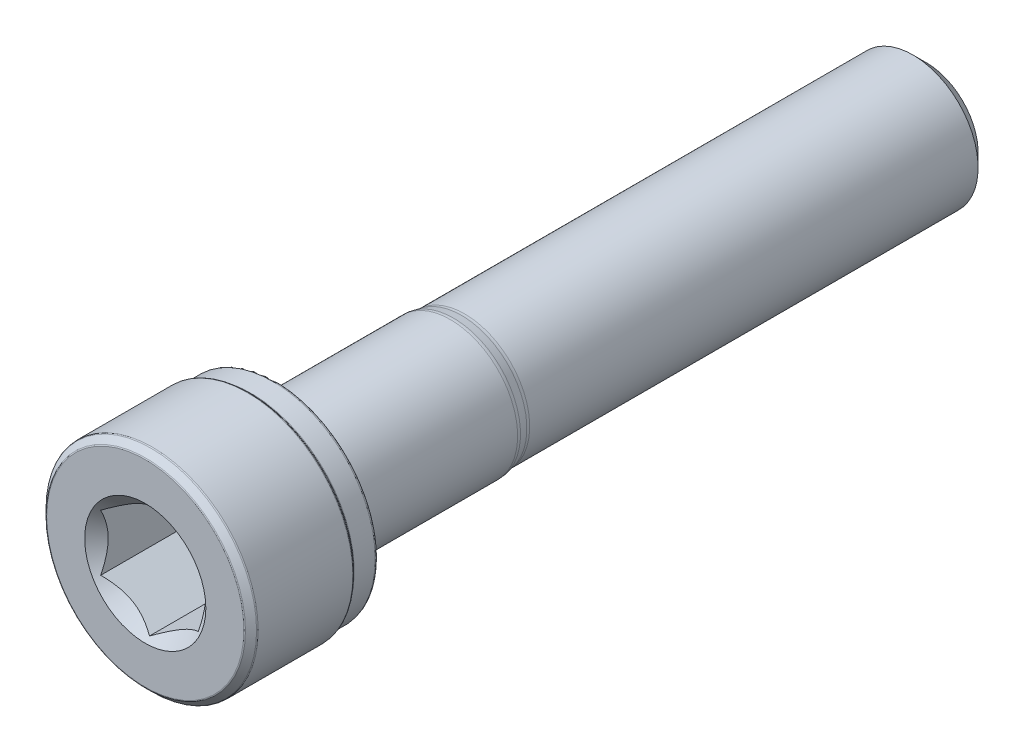
from build123d import *

# Parameters (mm, degrees)
CUT_EXTRUDE1_DEPTH = 7


with BuildPart() as part:
    # Sketch2 → Revolve1 (revolve)
    with BuildSketch(Plane(origin=(0, 0, 0), x_dir=(0, 0, -1), z_dir=(1, 0, 0)), mode=Mode.PRIVATE) as revolve1_sk:
        with BuildLine():
            Line((-24, 0), (-24, 6.058578644))
            ThreePointArc((-24, 6.058578644), (-23.992387953, 6.096846987), (-23.970710678, 6.129289322))
            Line((-23.970710678, 6.129289322), (-23.629289322, 6.470710678))
            ThreePointArc((-23.629289322, 6.470710678), (-23.596846987, 6.492387953), (-23.558578644, 6.5))
            Line((-23.558578644, 6.5), (-17.741421356, 6.5))
            ThreePointArc((-17.741421356, 6.5), (-17.703153013, 6.492387953), (-17.670710678, 6.470710678))
            Line((-17.670710678, 6.470710678), (-17.529289322, 6.329289322))
            ThreePointArc((-17.529289322, 6.329289322), (-17.496846987, 6.307612047), (-17.458578644, 6.3))
            Line((-17.458578644, 6.3), (-16.1625, 6.3))
            ThreePointArc((-16.1625, 6.3), (-16.047595148, 6.252404852), (-16, 6.1375))
            Line((-16, 6.1375), (-16, 4.535316469))
            ThreePointArc((-16, 4.535316469), (-15.882842712, 4.252473757), (-15.6, 4.135316469))
            Line((-15.6, 4.135316469), (-5.247523234, 4.135316469))
            ThreePointArc((-5.247523234, 4.135316469), (-5.149506093, 4.130501196), (-5.052432912, 4.11610175))
            Line((-5.052432912, 4.11610175), (-4.565348919, 4.01921472))
            ThreePointArc((-4.565348919, 4.01921472), (-4.468275737, 4.004815273), (-4.370258597, 4))
            Line((-4.370258597, 4), (23.188101184, 4))
            Line((23.188101184, 4), (24, 3.188101184))
            Line((24, 3.188101184), (24, 0))
            Line((24, 0), (-24, 0))
        make_face()
    revolve(revolve1_sk.sketch.rotate(Axis((0, 0, -24), (0, 0, 1)), 90), axis=Axis((0, 0, -24), (0, 0, 1)))

    # Sketch3 → Cut-Extrude1 (cut)
    with BuildSketch(Plane.XY.offset(24)):
        Polygon((3, -1.732050808), (3, 1.732050808), (0, 3.464101615), (-3, 1.732050808), (-3, -1.732050808), (0, -3.464101615), align=None)
    extrude(amount=-CUT_EXTRUDE1_DEPTH, mode=Mode.SUBTRACT)

    # Cut-Extrude2 cone 1 section (through the dimple's axis) → Cut-Extrude2 (revolve, cut)
    with BuildSketch(Plane(origin=(0, 0, 24), x_dir=(0, -1, 0), z_dir=(1, 0, 0))):
        Polygon((0, 0), (3.723909236, 0), (0, 3.723909236), align=None)
    revolve(axis=Axis((0, 0, 24), (0, 0, -1)), mode=Mode.SUBTRACT)


solid = part.part
